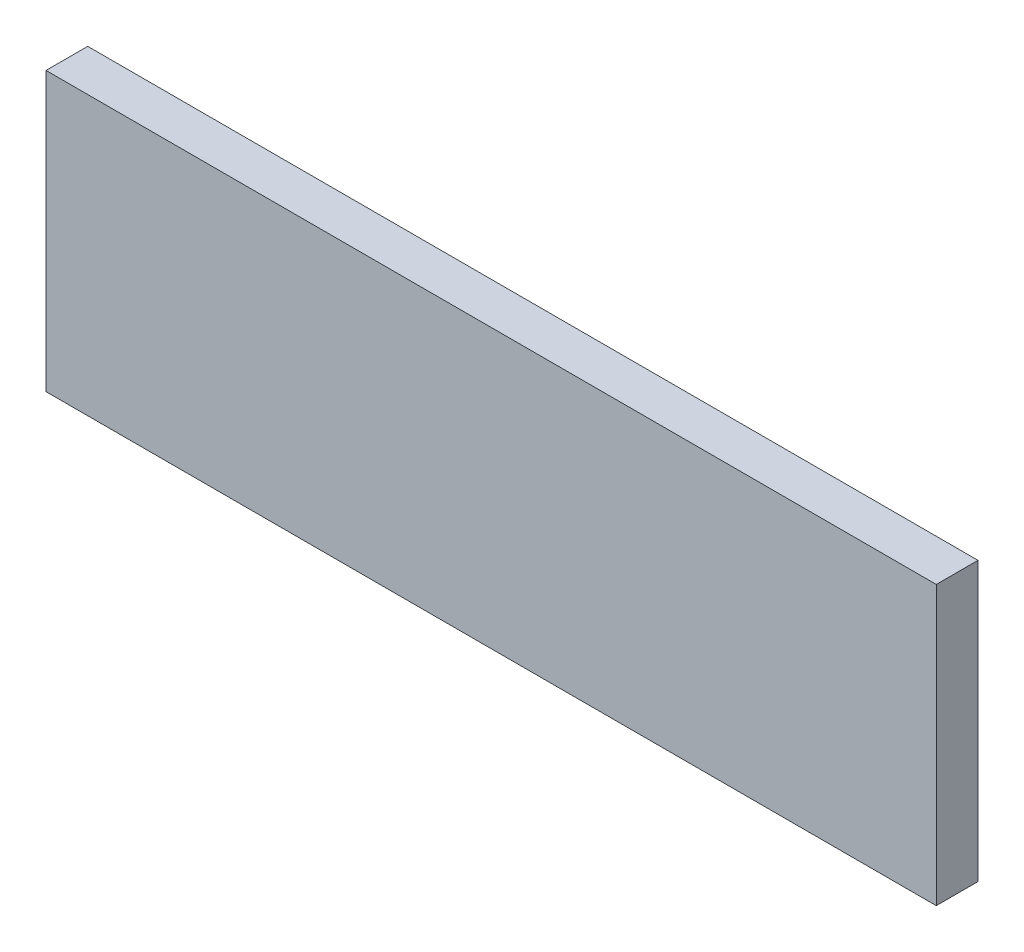
from build123d import *

# Parameters (mm, degrees)
SKETCH_1_W      = 320
SKETCH_1_H      = 15
EXTRUDE_1_DEPTH = 100


with BuildPart() as part:
    # 草图1 → 凸台-拉伸1 (new body)
    with BuildSketch(Plane(origin=(0, 0, 0), x_dir=(1, 0, 0), z_dir=(0, 1, 0))):
        with Locations((160, 7.5)):
            Rectangle(SKETCH_1_W, SKETCH_1_H)
    extrude(amount=EXTRUDE_1_DEPTH)


solid = part.part
